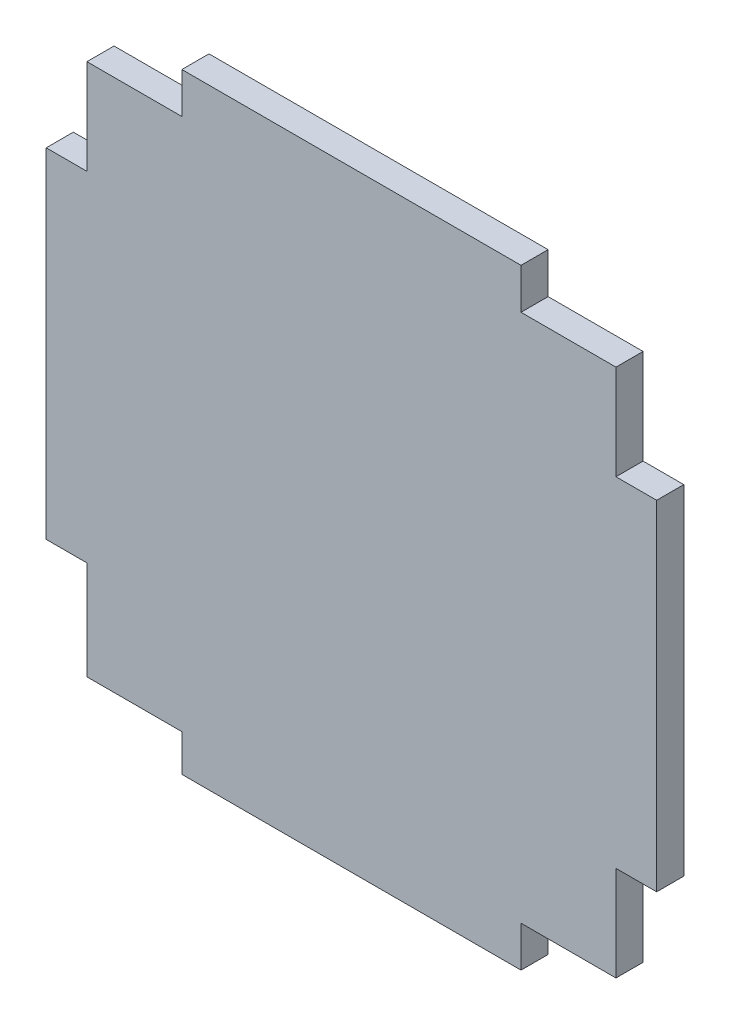
from build123d import *

# Parameters (mm, degrees)
SKETCH1_W           = 45
SKETCH1_H           = 45
BOSS_EXTRUDE1_DEPTH = 2
SKETCH2_W           = 7
SKETCH2_H           = 2.72647494
SKETCH2_H_2         = 3
SKETCH2_W_2         = 3
SKETCH2_H_3         = 7
CUT_EXTRUDE1_DEPTH  = 10


with BuildPart() as part:
    # Sketch1 → Boss-Extrude1 (new body)
    with BuildSketch(Plane.XY):
        Rectangle(SKETCH1_W, SKETCH1_H)
    extrude(amount=BOSS_EXTRUDE1_DEPTH)

    # Sketch2 → Cut-Extrude1 (cut)
    with BuildSketch(Plane.XY.offset(2)):
        Polygon((-22.5, -12.5), (-22.5, -22.5), (-19.5, -22.5), (-19.5, -19.77352506), (-19.5, -12.5), align=None)
        with Locations((-16, -21.13676253)):
            Rectangle(SKETCH2_W, SKETCH2_H)
        Polygon((19.5, -22.5), (22.5, -22.5), (22.5, -12.5), (19.5, -12.5), (19.5, -19.5), align=None)
        with Locations((16, -21)):
            Rectangle(SKETCH2_W, SKETCH2_H_2)
        Polygon((-12.5, 22.5), (-22.5, 22.5), (-22.5, 19.5), (-19.5, 19.5), (-12.5, 19.5), align=None)
        with Locations((-21, 16)):
            Rectangle(SKETCH2_W_2, SKETCH2_H_3)
        Polygon((22.5, 12.5), (22.5, 22.5), (19.5, 22.5), (19.5, 19.5), (19.5, 12.5), align=None)
        with Locations((16, 21)):
            Rectangle(SKETCH2_W, SKETCH2_H_2)
    extrude(amount=-CUT_EXTRUDE1_DEPTH, mode=Mode.SUBTRACT)


solid = part.part
